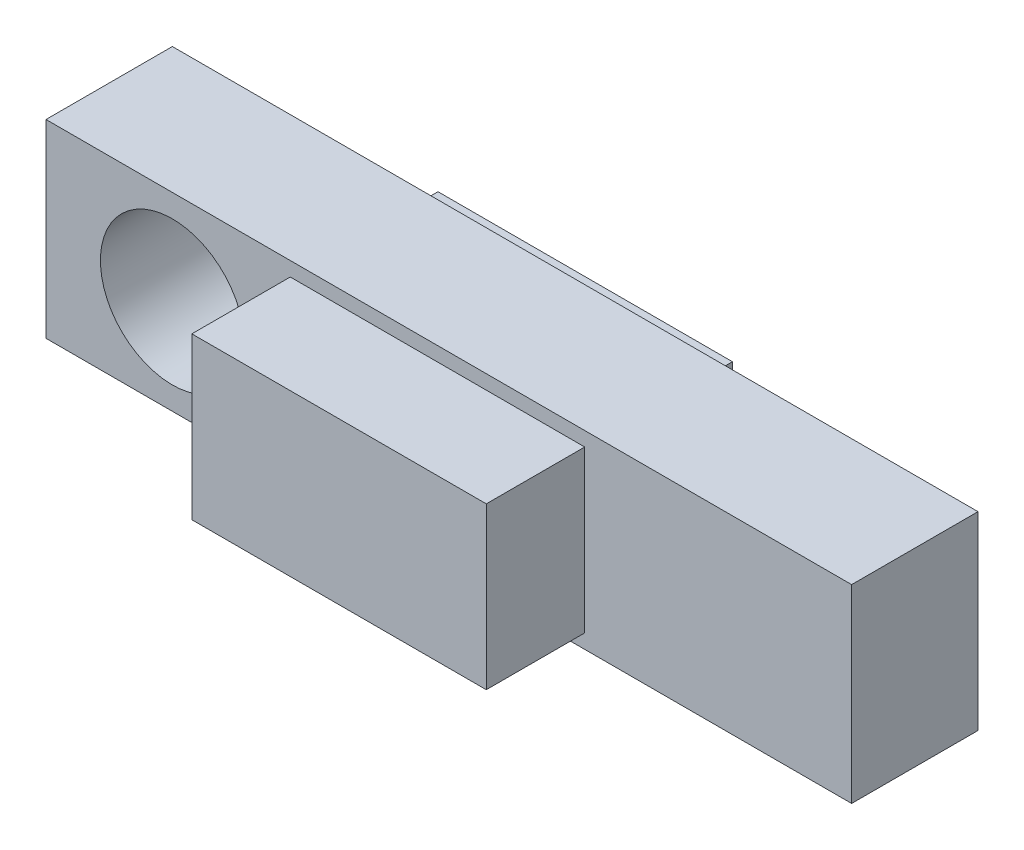
from build123d import *

# Parameters (mm, degrees)
SKETCH1_W           = 161.925
SKETCH1_H           = 38.1
BOSS_EXTRUDE1_DEPTH = 25.4
SKETCH3_W           = 59.182
SKETCH3_H           = 32.3596
BOSS_EXTRUDE3_DEPTH = 19.7866
SKETCH4_W           = 59.182
SKETCH4_H           = 32.3596
BOSS_EXTRUDE4_DEPTH = 4.2926
SKETCH6_R           = 14.4653
CUT_EXTRUDE1_DEPTH  = 30.6926


with BuildPart() as part:
    # Sketch1 → Boss-Extrude1 (new body)
    with BuildSketch(Plane.XY):
        with Locations((80.9625, 0)):
            Rectangle(SKETCH1_W, SKETCH1_H)
    extrude(amount=BOSS_EXTRUDE1_DEPTH)

    # Sketch3 → Boss-Extrude3 (add)
    with BuildSketch(Plane.XY.offset(25.4)):
        with Locations((78.6892, 0)):
            Rectangle(SKETCH3_W, SKETCH3_H)
    extrude(amount=BOSS_EXTRUDE3_DEPTH)

    # Sketch4 → Boss-Extrude4 (add)
    with BuildSketch(Plane(origin=(0, 0, 0), x_dir=(-1, 0, 0), z_dir=(0, 0, -1))):
        with Locations((-78.6892, 0)):
            Rectangle(SKETCH4_W, SKETCH4_H)
    extrude(amount=BOSS_EXTRUDE4_DEPTH)

    # Sketch6 → Cut-Extrude1 (cut, through all)
    with BuildSketch(Plane.XY.offset(25.4)):
        with Locations((25.4, 0)):
            Circle(SKETCH6_R)
    extrude(amount=-CUT_EXTRUDE1_DEPTH, mode=Mode.SUBTRACT)


solid = part.part
